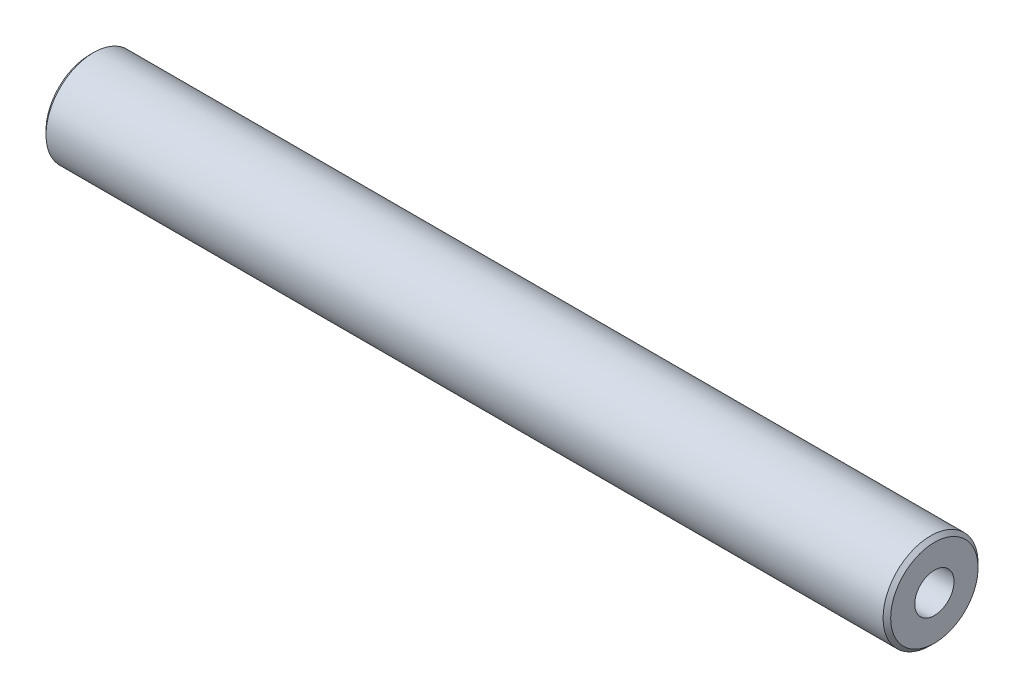
from build123d import *

# Parameters (mm, degrees)
SKETCH1_W     = 88.9
SKETCH1_H     = 5
CHAMFER1_SIZE = 0.4
TAP4_D        = 4.134
TAP4_DEPTH    = 12.4
TAP4_TIP      = 1.2419789
TAP5_D        = 4.134
TAP5_DEPTH    = 12.4
TAP5_TIP      = 1.2419789


with BuildPart() as part:
    # Sketch1 → Revolve1 (revolve)
    with BuildSketch(Plane.XY):
        with Locations((44.45, 2.5)):
            Rectangle(SKETCH1_W, SKETCH1_H)
    revolve(axis=Axis((0, 0, 0), (1, 0, 0)))

    # Chamfer1
    chamfer1_edges = [part.edges().sort_by_distance(p)[0] for p in [
        (88.9, -5, 0),
        (0, -5, 0),
    ]]
    chamfer(chamfer1_edges, length=CHAMFER1_SIZE)

    # Tap4
    with Locations(Plane.ZY):
        with Locations((0, 0)):
            Hole(TAP4_D / 2, depth=TAP4_DEPTH)
            with Locations((0, 0, -(TAP4_DEPTH + TAP4_TIP / 2))):  # 118° drill point
                Cone(0, TAP4_D / 2, TAP4_TIP, mode=Mode.SUBTRACT)

    # Tap5
    with Locations(Plane(origin=(88.9, 0, 0), x_dir=(0, 0, -1), z_dir=(1, 0, 0))):
        with Locations((0, 0)):
            Hole(TAP5_D / 2, depth=TAP5_DEPTH)
            with Locations((0, 0, -(TAP5_DEPTH + TAP5_TIP / 2))):  # 118° drill point
                Cone(0, TAP5_D / 2, TAP5_TIP, mode=Mode.SUBTRACT)


solid = part.part
